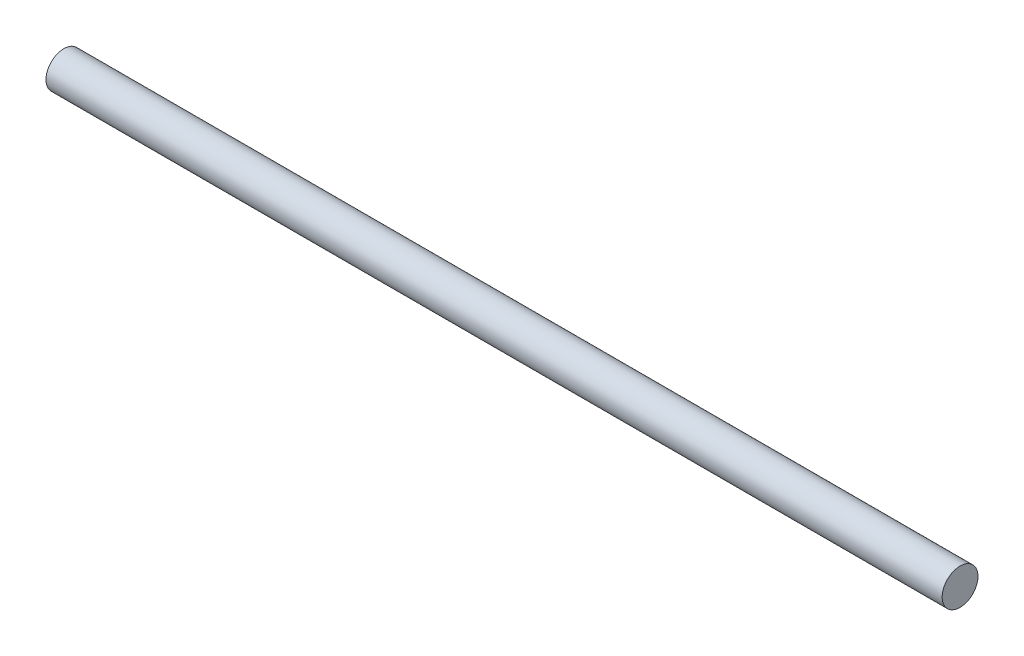
from build123d import *

# Parameters (mm, degrees)
SKETCH1_R           = 4
BOSS_EXTRUDE1_DEPTH = 200


with BuildPart() as part:
    # Sketch1 → Boss-Extrude1 (new body)
    with BuildSketch(Plane(origin=(0, 0, 0), x_dir=(0, 0, -1), z_dir=(1, 0, 0))):
        Circle(SKETCH1_R)
    extrude(amount=BOSS_EXTRUDE1_DEPTH)


solid = part.part
